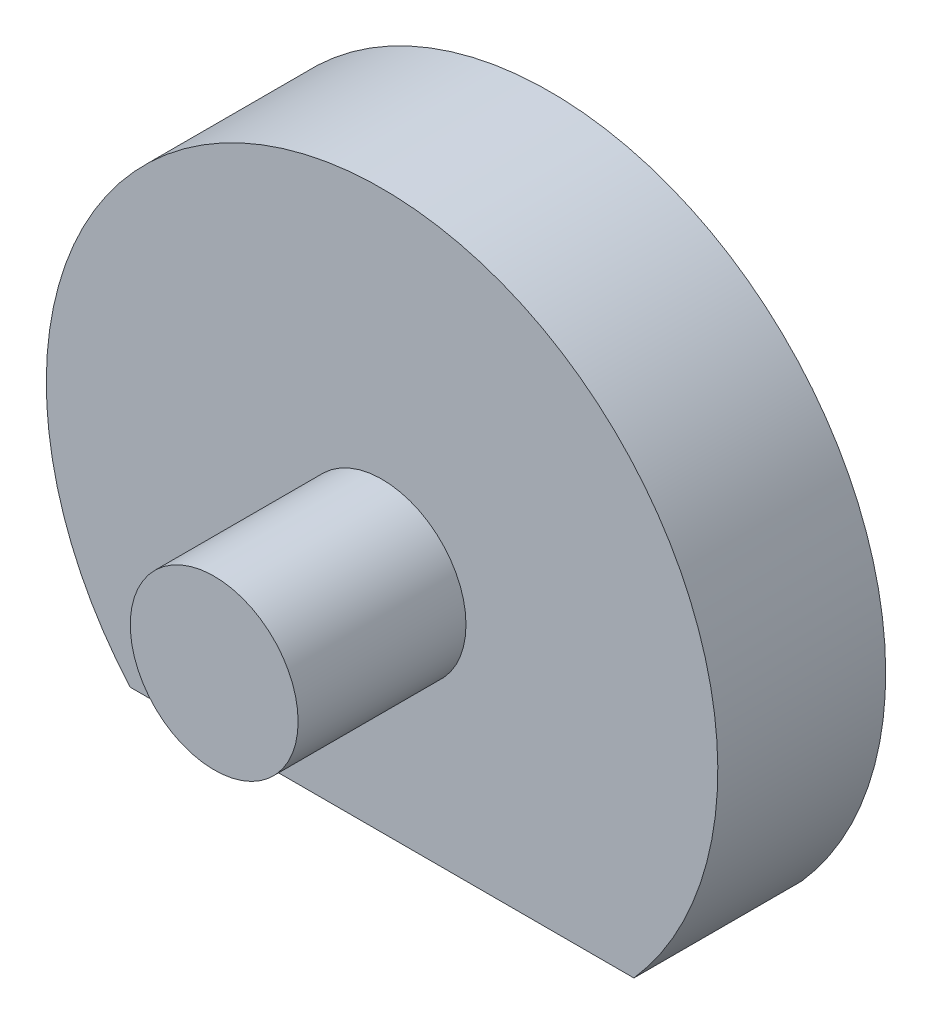
from build123d import *

# Parameters (mm, degrees)
SKETCH1_R           = 2.5
BOSS_EXTRUDE1_DEPTH = 10
BOSS_EXTRUDE2_START = -5
SKETCH1_3_R         = 2.5
BOSS_EXTRUDE2_DEPTH = 5


with BuildPart() as part:
    # Sketch1 → Boss-Extrude1 (new body)
    with BuildSketch(Plane.XY):
        with Locations((-79.564743262, 27.357918419)):
            Circle(SKETCH1_R)
    extrude(amount=-BOSS_EXTRUDE1_DEPTH)

    # Sketch1_3 → Boss-Extrude2 (add)
    with BuildSketch(Plane.XY.offset(BOSS_EXTRUDE2_START)):
        with BuildLine():
            ThreePointArc((-72.064743262, 20.743540142), (-79.564743262, 37.357918419), (-87.064743262, 20.743540142))
            Line((-87.064743262, 20.743540142), (-72.064743262, 20.743540142))
        make_face()
        with Locations((-79.564743262, 27.357918419)):
            Circle(SKETCH1_3_R, mode=Mode.SUBTRACT)
    extrude(amount=-BOSS_EXTRUDE2_DEPTH)


solid = part.part
